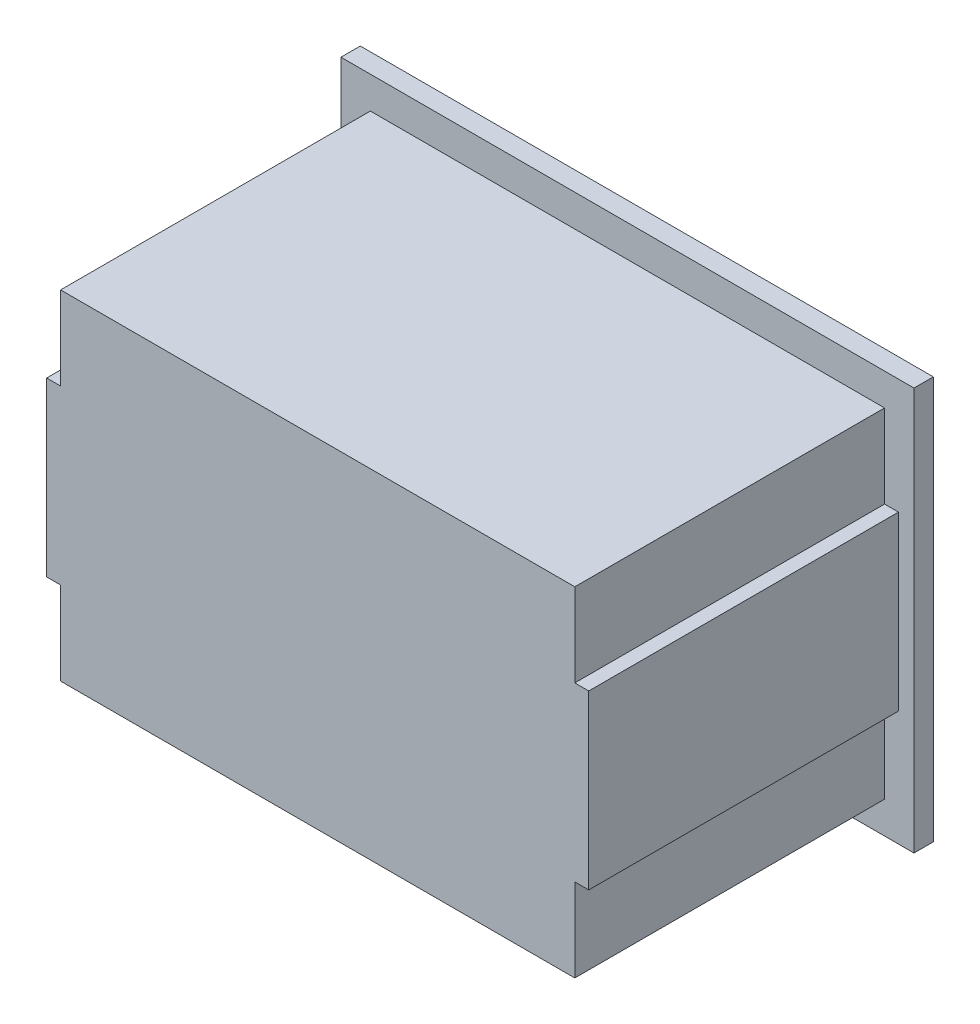
from build123d import *

# Parameters (mm, degrees)
SKETCH1_W           = 13.28
SKETCH1_H           = 8.75
BOSS_EXTRUDE1_DEPTH = 8
SKETCH2_W           = 14.8
SKETCH2_H           = 10.4
BOSS_EXTRUDE2_DEPTH = 1
CHAMFER2_SIZE       = 0.5
SKETCH3_W           = 14
SKETCH3_H           = 4.45
BOSS_EXTRUDE3_DEPTH = 8


with BuildPart() as part:
    # Sketch1 → Boss-Extrude1 (new body)
    with BuildSketch(Plane.XY):
        Rectangle(SKETCH1_W, SKETCH1_H)
    extrude(amount=BOSS_EXTRUDE1_DEPTH)

    # Sketch2 → Boss-Extrude2 (add)
    with BuildSketch(Plane(origin=(0, 0, 0), x_dir=(-1, 0, 0), z_dir=(0, 0, -1))):
        Rectangle(SKETCH2_W, SKETCH2_H)
    extrude(amount=BOSS_EXTRUDE2_DEPTH)

    # Chamfer2
    chamfer2_edges = [part.edges().sort_by_distance(p)[0] for p in [
        (7.4, 0, -1),
        (0, -5.2, -1),
        (-7.4, 0, -1),
        (0, 5.2, -1),
    ]]
    chamfer(chamfer2_edges, length=CHAMFER2_SIZE)

    # Sketch3 → Boss-Extrude3 (add)
    with BuildSketch(Plane.XY.offset(8)):
        Rectangle(SKETCH3_W, SKETCH3_H)
    extrude(amount=-BOSS_EXTRUDE3_DEPTH)


solid = part.part
